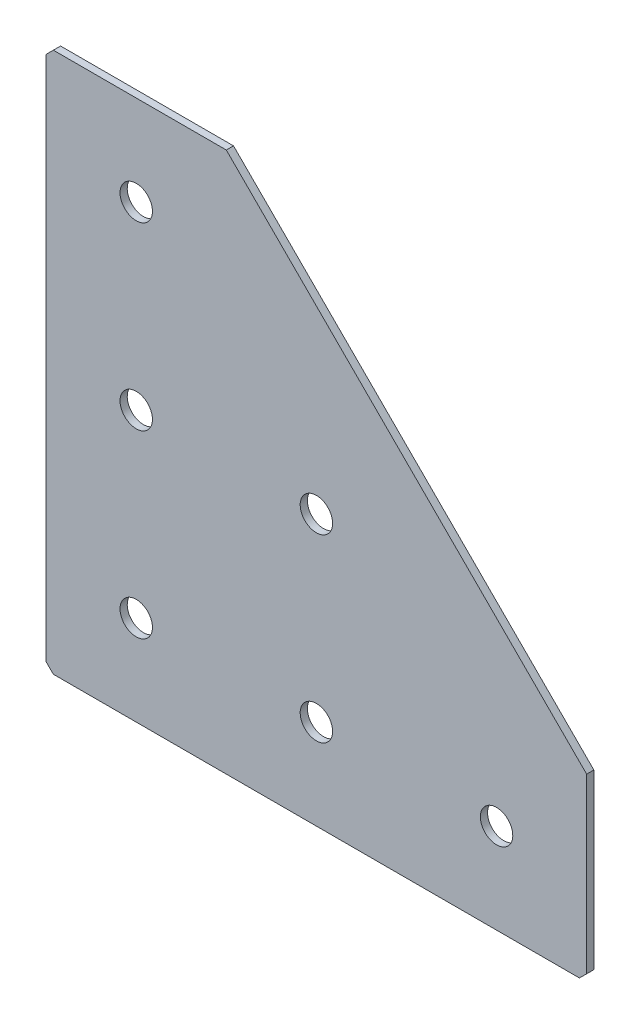
from build123d import *

# Parameters (mm, degrees)
EXTRUDE_1_DEPTH   = 2
HOLE_WIZARD_M81_D = 9
CHAMFER_1_SIZE    = 2


with BuildPart() as part:
    # Эскиз1 → Бобышка-Вытянуть1 (new body)
    with BuildSketch(Plane(origin=(0, 0, 0), x_dir=(1, 0, 0), z_dir=(0, 0, -1))):
        Polygon((0, 0), (0, 150), (150, 150), (150, 100), (50, 0), align=None)
    extrude(amount=EXTRUDE_1_DEPTH)

    # Отверстие с зазором M81 (through all)
    with Locations(Plane(origin=(0, 0, -2), x_dir=(1, 0, 0), z_dir=(0, 0, -1))):
        with Locations((75, 125), (25, 125), (25, 75), (25, 25), (125, 125), (75, 75)):
            Hole(HOLE_WIZARD_M81_D / 2)

    # Фаска1
    chamfer_1_edges = [part.edges().sort_by_distance(p)[0] for p in [
        (0, 0, -1),
        (0, -150, -1),
        (150, -150, -1),
    ]]
    chamfer(chamfer_1_edges, length=CHAMFER_1_SIZE)


solid = part.part
